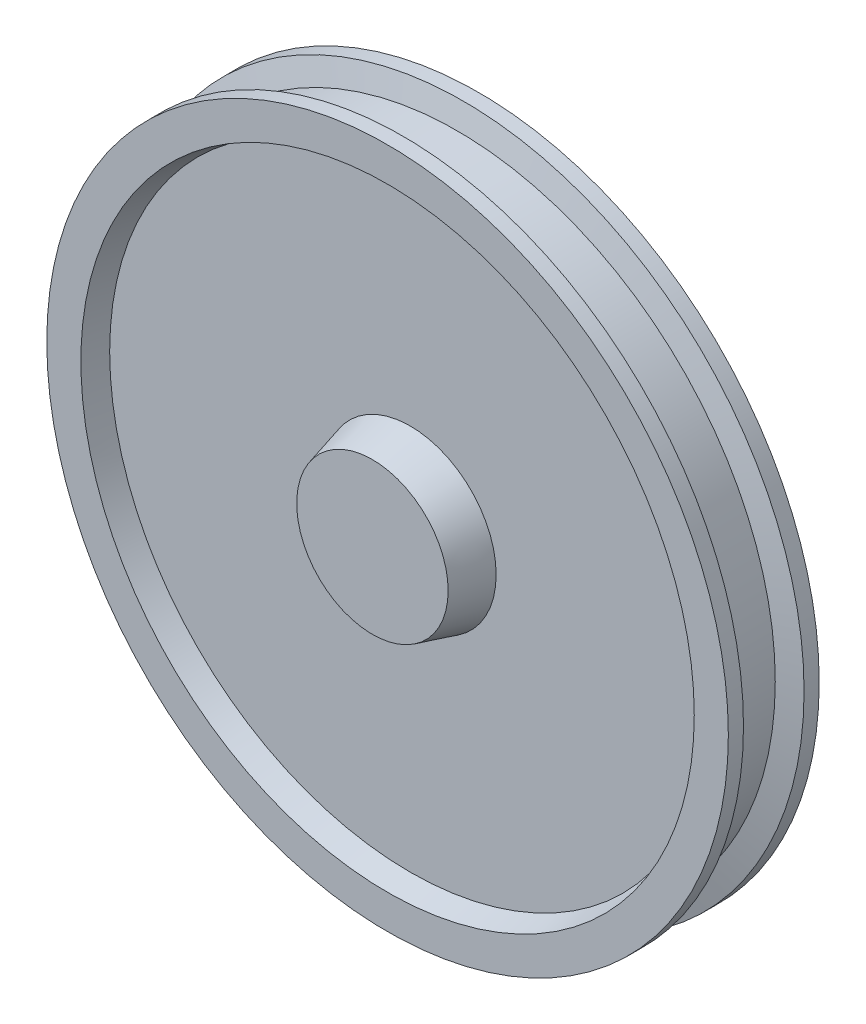
from build123d import *


with BuildPart() as part:
    # Sketch1 → Revolve1 (revolve)
    with BuildSketch(Plane(origin=(0, 0, 0), x_dir=(0, 0, -1), z_dir=(1, 0, 0))):
        Polygon((-80, 0), (-80, 100), (-30, 113.397459622), (-30, 396.961524227), (-60, 405), (-60, 450), (-40, 450), (-31.961524227, 420), (31.961524227, 420), (40, 450), (60, 450), (60, 405), (30, 396.961524227), (30, 113.397459622), (80, 100), (80, 0), align=None)
    revolve(axis=Axis((0, 0, 80), (0, 0, -1)))


solid = part.part
